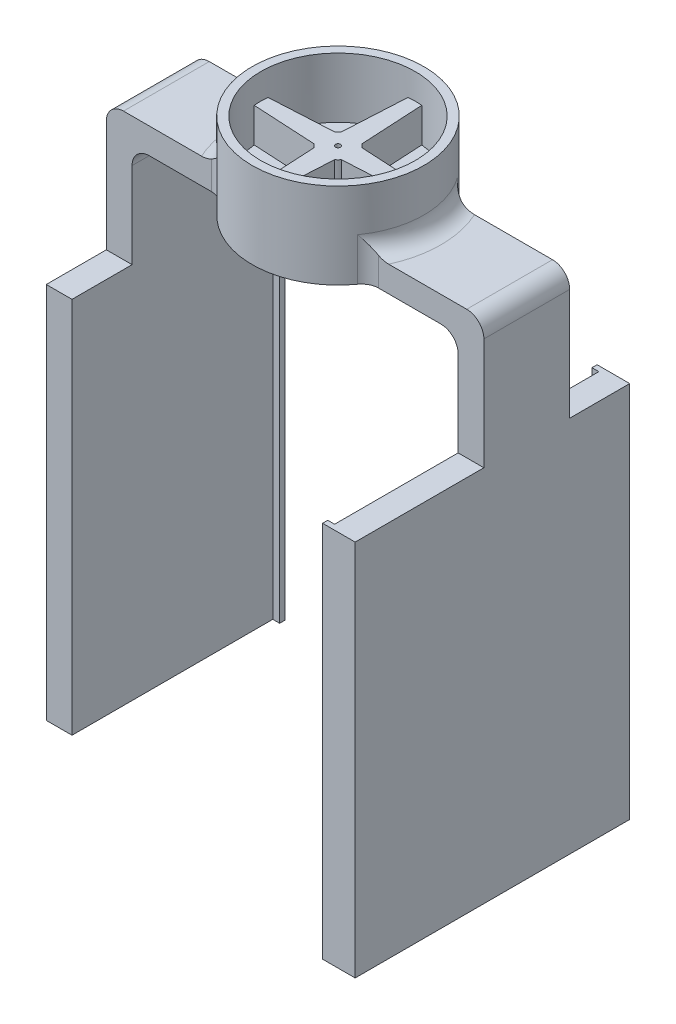
from build123d import *

# Parameters (mm, degrees)
SKETCH1_R                = 25
BOSS_EXTRUDE1_DEPTH      = 25
BOSS_EXTRUDE3_DEPTH      = 55
BOSS_EXTRUDE3_DEPTH_BACK = 55
SKETCH9_W                = 25
SKETCH9_H                = 7.5
SKETCH16_R               = 22.5
CUT_EXTRUDE3_DEPTH       = 7.5
SKETCH17_R               = 0.75
CUT_EXTRUDE4_DEPTH       = 10
SKETCH22_W               = 7.5
SKETCH22_H               = 25
BOSS_EXTRUDE7_DEPTH      = 30
SKETCH23_W               = 7.5
SKETCH23_H               = 60
BOSS_EXTRUDE8_DEPTH      = 110
SKETCH24_W               = 7.5
SKETCH24_H               = 80
BOSS_EXTRUDE9_DEPTH      = 110
SKETCH25_W               = 1.5
SKETCH25_H               = 110
BOSS_EXTRUDE10_DEPTH     = 2
SKETCH26_W               = 1.5
SKETCH26_H               = 110
BOSS_EXTRUDE11_DEPTH     = 2
FILLET6_R                = 5


with BuildPart() as part:
    # Sketch1 → Boss-Extrude1 (new body)
    with BuildSketch(Plane(origin=(0, 0, 0), x_dir=(1, 0, 0), z_dir=(0, 1, 0))):
        Circle(SKETCH1_R)
    extrude(amount=BOSS_EXTRUDE1_DEPTH)

    # Sketch9 → Boss-Extrude3 (add, two sides: drawn at the far end of the back side and taken through both)
    with BuildSketch(Plane(origin=(0, 0, 0), x_dir=(0, 0, -1), z_dir=(1, 0, 0)).offset(-BOSS_EXTRUDE3_DEPTH_BACK)):
        with Locations((0, 3.75)):
            Rectangle(SKETCH9_W, SKETCH9_H)
    extrude(amount=BOSS_EXTRUDE3_DEPTH + BOSS_EXTRUDE3_DEPTH_BACK)

    # Sketch16 → Cut-Extrude3 (cut)
    with BuildSketch(Plane(origin=(0, 25, 0), x_dir=(1, 0, 0), z_dir=(0, 1, 0))):
        Circle(SKETCH16_R)
    extrude(amount=-CUT_EXTRUDE3_DEPTH, mode=Mode.SUBTRACT)

    # Sketch17 → Cut-Extrude4 (cut)
    with BuildSketch(Plane(origin=(0, 17.5, 0), x_dir=(1, 0, 0), z_dir=(0, 1, 0))):
        with BuildLine():
            ThreePointArc((-4, 3), (-3.535533906, 3.535533906), (-3, 4))
            Line((-3, 4), (-2, 22.410934831))
            ThreePointArc((-2, 22.410934831), (-15.909902577, 15.909902577), (-22.410934831, 2))
            Line((-22.410934831, 2), (-4, 3))
        make_face()
        Circle(SKETCH17_R)
        with BuildLine():
            ThreePointArc((22.410934831, 2), (15.909902577, 15.909902577), (2, 22.410934831))
            Line((2, 22.410934831), (3, 4))
            ThreePointArc((3, 4), (3.535533906, 3.535533906), (4, 3))
            Line((4, 3), (22.410934831, 2))
        make_face()
        with BuildLine():
            ThreePointArc((-3, -4), (-3.535533906, -3.535533906), (-4, -3))
            Line((-4, -3), (-22.410934831, -2))
            ThreePointArc((-22.410934831, -2), (-15.909902577, -15.909902577), (-2, -22.410934831))
            Line((-2, -22.410934831), (-3, -4))
        make_face()
        with BuildLine():
            ThreePointArc((4, -3), (3.535533906, -3.535533906), (3, -4))
            Line((3, -4), (2, -22.410934831))
            ThreePointArc((2, -22.410934831), (15.909902577, -15.909902577), (22.410934831, -2))
            Line((22.410934831, -2), (4, -3))
        make_face()
    extrude(amount=-CUT_EXTRUDE4_DEPTH, mode=Mode.SUBTRACT)

    # Sketch22 → Boss-Extrude7 (add)
    with BuildSketch(Plane.XZ):
        with Locations((-51.25, 0)):
            Rectangle(SKETCH22_W, SKETCH22_H)
    boss_extrude7 = extrude(amount=BOSS_EXTRUDE7_DEPTH)

    # Sketch23 → Boss-Extrude8 (add)
    with BuildSketch(Plane.XZ.offset(30)):
        with Locations((-51.25, 0)):
            Rectangle(SKETCH23_W, SKETCH23_H)
    extrude(amount=BOSS_EXTRUDE8_DEPTH)

    # Mirror1: Boss-Extrude7 across plane
    add(boss_extrude7.mirror(Plane(origin=(0, 0, 0), x_dir=(0, 0, 1), z_dir=(1, 0, 0))))

    # Sketch24 → Boss-Extrude9 (add)
    with BuildSketch(Plane.XZ.offset(30)):
        with Locations((51.25, 10)):
            Rectangle(SKETCH24_W, SKETCH24_H)
    extrude(amount=BOSS_EXTRUDE9_DEPTH)

    # Sketch25 → Boss-Extrude10 (add)
    with BuildSketch(Plane(origin=(-47.5, 0, 0), x_dir=(0, 0, -1), z_dir=(1, 0, 0))):
        with Locations((29.25, -85)):
            Rectangle(SKETCH25_W, SKETCH25_H)
    extrude(amount=BOSS_EXTRUDE10_DEPTH)

    # Sketch26 → Boss-Extrude11 (add)
    with BuildSketch(Plane.ZY.offset(-47.5)):
        with Locations((-29.25, -85)):
            Rectangle(SKETCH26_W, SKETCH26_H)
        with Locations((49.25, -85)):
            Rectangle(SKETCH26_W, SKETCH26_H)
    extrude(amount=BOSS_EXTRUDE11_DEPTH)

    # Fillet6
    fillet6_edges = [part.edges().sort_by_distance(p)[0] for p in [
        (55, 7.5, 0),
        (-55, 7.5, 0),
        (-47.5, 0, 0),
        (47.5, 0, 0),
        (24.148145657, 7.5, -6.470476128),
        (-25, 7.5, 0),
        (-21.650635095, 3.75, 12.5),
        (21.650635095, 3.75, 12.5),
        (-21.650635095, 3.75, -12.5),
        (21.650635095, 3.75, -12.5),
    ]]
    fillet(fillet6_edges, radius=FILLET6_R)


solid = part.part
